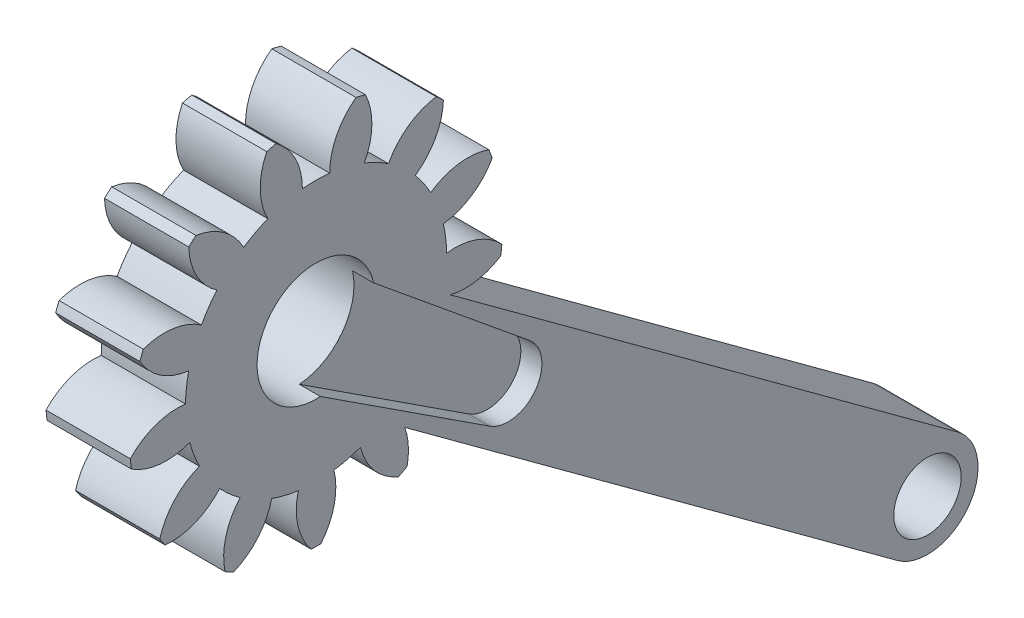
from build123d import *

# Parameters (mm, degrees)
SKETCH1_R           = 3.5
BOSS_EXTRUDE1_DEPTH = 5
SKETCH2_R           = 2
BOSS_EXTRUDE2_DEPTH = 5
CUT_EXTRUDE1_DEPTH  = 1.25


with BuildPart() as part:
    # Sketch1 → Boss-Extrude1 (new body)
    with BuildSketch(Plane(origin=(-2.712826585, 0, 0), x_dir=(0, 0, -1), z_dir=(1, 0, 0))):
        with BuildLine():
            ThreePointArc((-81.947812788, 41.849675859), (-81.477011433, 40.124136701), (-80.275497155, 38.799182837))
            ThreePointArc((-80.275497155, 38.799182837), (-80.771500839, 38.155576831), (-81.197397579, 37.463579494))
            ThreePointArc((-81.197397579, 37.463579494), (-82.862313797, 38.117179744), (-84.642669398, 37.94550204))
            ThreePointArc((-84.642669398, 37.94550204), (-84.747423061, 37.679683216), (-84.845284304, 37.411250441))
            ThreePointArc((-84.845284304, 37.411250441), (-83.626512376, 36.102153696), (-81.946887557, 35.48733684))
            ThreePointArc((-81.946887557, 35.48733684), (-82.086978383, 34.686947618), (-82.14250402, 33.876290323))
            ThreePointArc((-82.14250402, 33.876290323), (-83.920457299, 33.681299457), (-85.417101287, 32.701913897))
            ThreePointArc((-85.417101287, 32.701913897), (-85.386323881, 32.417861562), (-85.348228779, 32.134697757))
            ThreePointArc((-85.348228779, 32.134697757), (-83.660692239, 31.541941712), (-81.887738682, 31.778108996))
            ThreePointArc((-81.887738682, 31.778108996), (-81.63982353, 31.004296084), (-81.31225781, 30.260690647))
            ThreePointArc((-81.31225781, 30.260690647), (-82.795940481, 29.261778722), (-83.666009754, 27.699050735))
            ThreePointArc((-83.666009754, 27.699050735), (-83.506752013, 27.461837857), (-83.341427693, 27.228812437))
            ThreePointArc((-83.341427693, 27.228812437), (-81.571720826, 27.488190359), (-80.111600825, 28.521238704))
            ThreePointArc((-80.111600825, 28.521238704), (-79.532474069, 27.951273314), (-78.896858351, 27.44507078))
            ThreePointArc((-78.896858351, 27.44507078), (-79.746376594, 25.871076479), (-79.790548767, 24.083008214))
            ThreePointArc((-79.790548767, 24.083008214), (-79.53929472, 23.946977405), (-79.284614992, 23.817473685))
            ThreePointArc((-79.284614992, 23.817473685), (-77.838156313, 24.869565218), (-77.025365765, 26.462835698))
            ThreePointArc((-77.025365765, 26.462835698), (-76.247698364, 26.227290032), (-75.44964455, 26.074455301))
            ThreePointArc((-75.44964455, 26.074455301), (-75.470383973, 24.285961751), (-74.678539734, 22.682178099))
            ThreePointArc((-74.678539734, 22.682178099), (-74.392848655, 22.678492377), (-74.107157575, 22.682178099))
            ThreePointArc((-74.107157575, 22.682178099), (-73.315313337, 24.285961751), (-73.33605276, 26.074455301))
            ThreePointArc((-73.33605276, 26.074455301), (-72.537998945, 26.227290032), (-71.760331544, 26.462835698))
            ThreePointArc((-71.760331544, 26.462835698), (-70.947540996, 24.869565218), (-69.501082317, 23.817473685))
            ThreePointArc((-69.501082317, 23.817473685), (-69.246402589, 23.946977405), (-68.995148542, 24.083008214))
            ThreePointArc((-68.995148542, 24.083008214), (-69.039320715, 25.871076479), (-69.888838958, 27.44507078))
            ThreePointArc((-69.888838958, 27.44507078), (-69.25322324, 27.951273314), (-68.674096484, 28.521238704))
            ThreePointArc((-68.674096484, 28.521238704), (-67.213976483, 27.488190359), (-65.444269616, 27.228812437))
            ThreePointArc((-65.444269616, 27.228812437), (-65.278945296, 27.461837857), (-65.119687555, 27.699050735))
            ThreePointArc((-65.119687555, 27.699050735), (-65.989756828, 29.261778722), (-67.473439499, 30.260690647))
            ThreePointArc((-67.473439499, 30.260690647), (-67.145873779, 31.004296084), (-66.897958627, 31.778108996))
            ThreePointArc((-66.897958627, 31.778108996), (-65.12500507, 31.541941712), (-63.437468531, 32.134697757))
            ThreePointArc((-63.437468531, 32.134697757), (-63.399373428, 32.417861562), (-63.368596022, 32.701913897))
            ThreePointArc((-63.368596022, 32.701913897), (-64.86524001, 33.681299457), (-66.643193289, 33.876290323))
            ThreePointArc((-66.643193289, 33.876290323), (-66.698718926, 34.686947618), (-66.838809753, 35.48733684))
            ThreePointArc((-66.838809753, 35.48733684), (-65.159184933, 36.102153696), (-63.940413005, 37.411250441))
            ThreePointArc((-63.940413005, 37.411250441), (-64.038274248, 37.679683216), (-64.143027911, 37.94550204))
            ThreePointArc((-64.143027911, 37.94550204), (-65.923383512, 38.117179744), (-67.58829973, 37.463579494))
            ThreePointArc((-67.58829973, 37.463579494), (-68.01419647, 38.155576831), (-68.510200154, 38.799182837))
            ThreePointArc((-68.510200154, 38.799182837), (-67.308685876, 40.124136701), (-66.837884521, 41.849675859))
            ThreePointArc((-66.837884521, 41.849675859), (-67.049283279, 42.041882889), (-67.265570208, 42.228572314))
            ThreePointArc((-67.265570208, 42.228572314), (-68.92177941, 41.55321287), (-70.092246326, 40.200753443))
            ThreePointArc((-70.092246326, 40.200753443), (-70.790946358, 40.615562571), (-71.529234434, 40.954942982))
            ThreePointArc((-71.529234434, 40.954942982), (-71.081083139, 42.686502891), (-71.466107273, 44.433184235))
            ThreePointArc((-71.466107273, 44.433184235), (-71.742614638, 44.505133207), (-72.020886105, 44.569924936))
            ThreePointArc((-72.020886105, 44.569924936), (-73.173531339, 43.202245052), (-73.581409088, 41.460758605))
            ThreePointArc((-73.581409088, 41.460758605), (-74.392848655, 41.503351752), (-75.204288221, 41.460758605))
            ThreePointArc((-75.204288221, 41.460758605), (-75.61216597, 43.202245052), (-76.764811205, 44.569924936))
            ThreePointArc((-76.764811205, 44.569924936), (-77.043082671, 44.505133207), (-77.319590036, 44.433184235))
            ThreePointArc((-77.319590036, 44.433184235), (-77.70461417, 42.686502891), (-77.256462875, 40.954942982))
            ThreePointArc((-77.256462875, 40.954942982), (-77.994750951, 40.615562571), (-78.693450983, 40.200753443))
            ThreePointArc((-78.693450983, 40.200753443), (-79.863917899, 41.55321287), (-81.520127101, 42.228572314))
            ThreePointArc((-81.520127101, 42.228572314), (-81.73641403, 42.041882889), (-81.947812788, 41.849675859))
        make_face()
        with Locations((-74.392848655, 33.752711127)):
            Circle(SKETCH1_R, mode=Mode.SUBTRACT)
    extrude(amount=-BOSS_EXTRUDE1_DEPTH)

    # Sketch2 → Boss-Extrude2 (add)
    with BuildSketch(Plane(origin=(-2.712826585, 0, 0), x_dir=(0, 0, -1), z_dir=(1, 0, 0))):
        with BuildLine():
            Line((-36.340788792, 9.544432787), (-71.164417227, 35.104462035))
            ThreePointArc((-71.164417227, 35.104462035), (-71.527272682, 31.649420661), (-74.714649395, 30.267536198))
            Line((-74.714649395, 30.267536198), (-39.891020959, 4.70750695))
            ThreePointArc((-39.891020959, 4.70750695), (-35.697441957, 5.350853784), (-36.340788792, 9.544432787))
        make_face()
        with Locations((-38.115904876, 7.125969868)):
            Circle(SKETCH2_R, mode=Mode.SUBTRACT)
    extrude(amount=-BOSS_EXTRUDE2_DEPTH)

    # Sketch4 → Cut-Extrude1 (cut)
    with BuildSketch(Plane(origin=(-2.712826585, 0, 0), x_dir=(0, 0, -1), z_dir=(1, 0, 0))):
        with BuildLine():
            Line((-0.915831104, -5.866675378), (-4.542476407, -4.193411072))
            ThreePointArc((-4.542476407, -4.193411072), (-3.521318412, -6.746986699), (-0.915831104, -5.866675378))
        make_face()
        with BuildLine():
            ThreePointArc((-70.977992994, 34.520018639), (-71.581978602, 31.667283222), (-74.137028803, 30.262072761))
            Line((-74.137028803, 30.262072761), (-64.084174194, 23.709202076))
            Line((-64.084174194, 23.709202076), (-61.723827508, 26.931178659))
            Line((-61.723827508, 26.931178659), (-70.977992994, 34.520018639))
        make_face()
        with BuildLine():
            Line((-61.723827508, 26.931178659), (-64.084174194, 23.709202076))
            ThreePointArc((-64.084174194, 23.709202076), (-61.378637545, 24.202743939), (-61.723827508, 26.931178659))
        make_face()
    extrude(amount=-CUT_EXTRUDE1_DEPTH, mode=Mode.SUBTRACT)


solid = part.part
